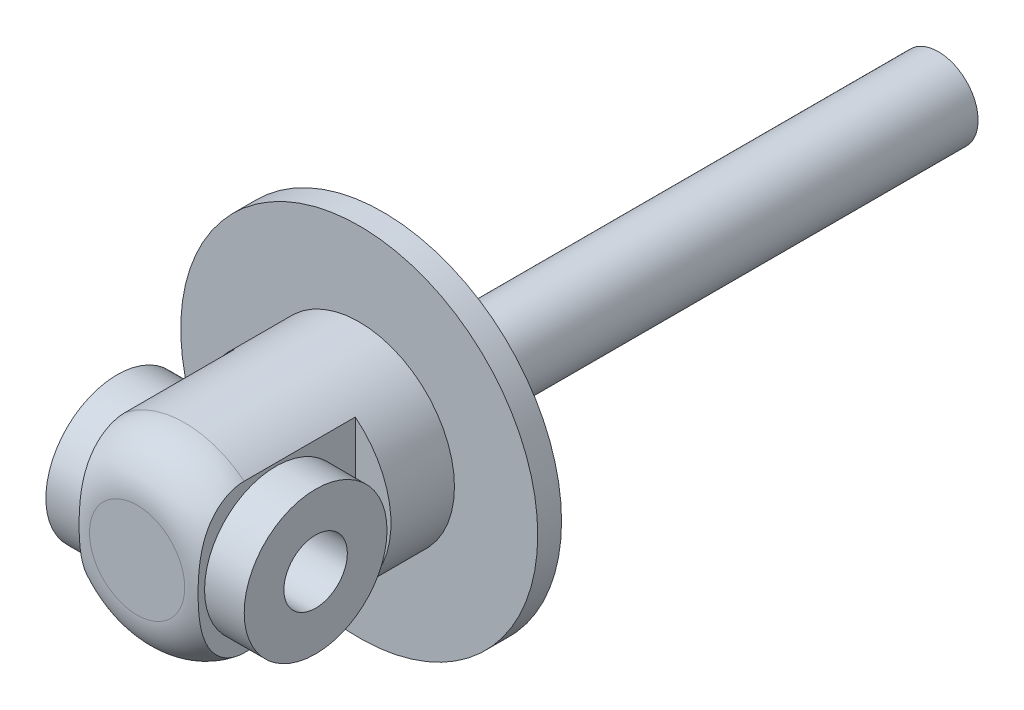
from build123d import *

# Parameters (mm, degrees)
SKETCH1_R               = 22.5
BOSS_EXTRUDE1_DEPTH     = 3
SKETCH2_R               = 5
BOSS_EXTRUDE2_DEPTH     = 70
SKETCH3_R               = 12
BOSS_EXTRUDE3_DEPTH     = 28
FILLET1_R               = 6
SKETCH4_W               = 19.57
SKETCH4_H               = 20
CUT_EXTRUDE1_DEPTH      = 23.5
CUT_EXTRUDE1_DEPTH_BACK = 23.5
SKETCH5_R               = 4
CUT_EXTRUDE2_DEPTH      = 16
CUT_EXTRUDE2_DEPTH_BACK = 31
SKETCH6_R               = 9
SKETCH6_R_2             = 4
BOSS_EXTRUDE4_DEPTH     = 12.5


with BuildPart() as part:
    # Sketch1 → Boss-Extrude1 (new body)
    with BuildSketch(Plane.XY):
        Circle(SKETCH1_R)
    extrude(amount=-BOSS_EXTRUDE1_DEPTH)

    # Sketch2 → Boss-Extrude2 (add)
    with BuildSketch(Plane(origin=(0, 0, -3), x_dir=(-1, 0, 0), z_dir=(0, 0, -1))):
        Circle(SKETCH2_R)
    extrude(amount=BOSS_EXTRUDE2_DEPTH)

    # Sketch3 → Boss-Extrude3 (add)
    with BuildSketch(Plane.XY):
        Circle(SKETCH3_R)
    extrude(amount=BOSS_EXTRUDE3_DEPTH)

    # Fillet1
    fillet1_edges = [part.edges().sort_by_distance(p)[0] for p in [
        (-12, 0, 28),
    ]]
    fillet(fillet1_edges, radius=FILLET1_R)

    # Sketch4 → Cut-Extrude1 (cut, two sides)
    with BuildSketch(Plane(origin=(0, 0, 0), x_dir=(1, 0, 0), z_dir=(0, 1, 0))) as cut_extrude1_sk:
        with Locations((17.285, -18)):
            Rectangle(SKETCH4_W, SKETCH4_H)
        with Locations((-17.285, -18)):
            Rectangle(SKETCH4_W, SKETCH4_H)
    extrude(amount=CUT_EXTRUDE1_DEPTH, mode=Mode.SUBTRACT)
    extrude(cut_extrude1_sk.sketch, amount=-CUT_EXTRUDE1_DEPTH_BACK, mode=Mode.SUBTRACT)

    # Sketch5 → Cut-Extrude2 (cut, two sides)
    with BuildSketch(Plane(origin=(7.5, 0, 0), x_dir=(0, 0, -1), z_dir=(1, 0, 0))) as cut_extrude2_sk:
        with Locations((-18, 0)):
            Circle(SKETCH5_R)
    extrude(amount=CUT_EXTRUDE2_DEPTH, mode=Mode.SUBTRACT)
    extrude(cut_extrude2_sk.sketch, amount=-CUT_EXTRUDE2_DEPTH_BACK, mode=Mode.SUBTRACT)

    # Sketch6 → Boss-Extrude4 (add, symmetric)
    with BuildSketch(Plane(origin=(0, 0, 0), x_dir=(0, 0, -1), z_dir=(1, 0, 0))):
        with Locations((-18, 0)):
            Circle(SKETCH6_R)
        with Locations((-18, 0)):
            Circle(SKETCH6_R_2, mode=Mode.SUBTRACT)
    extrude(amount=BOSS_EXTRUDE4_DEPTH, both=True)


solid = part.part
